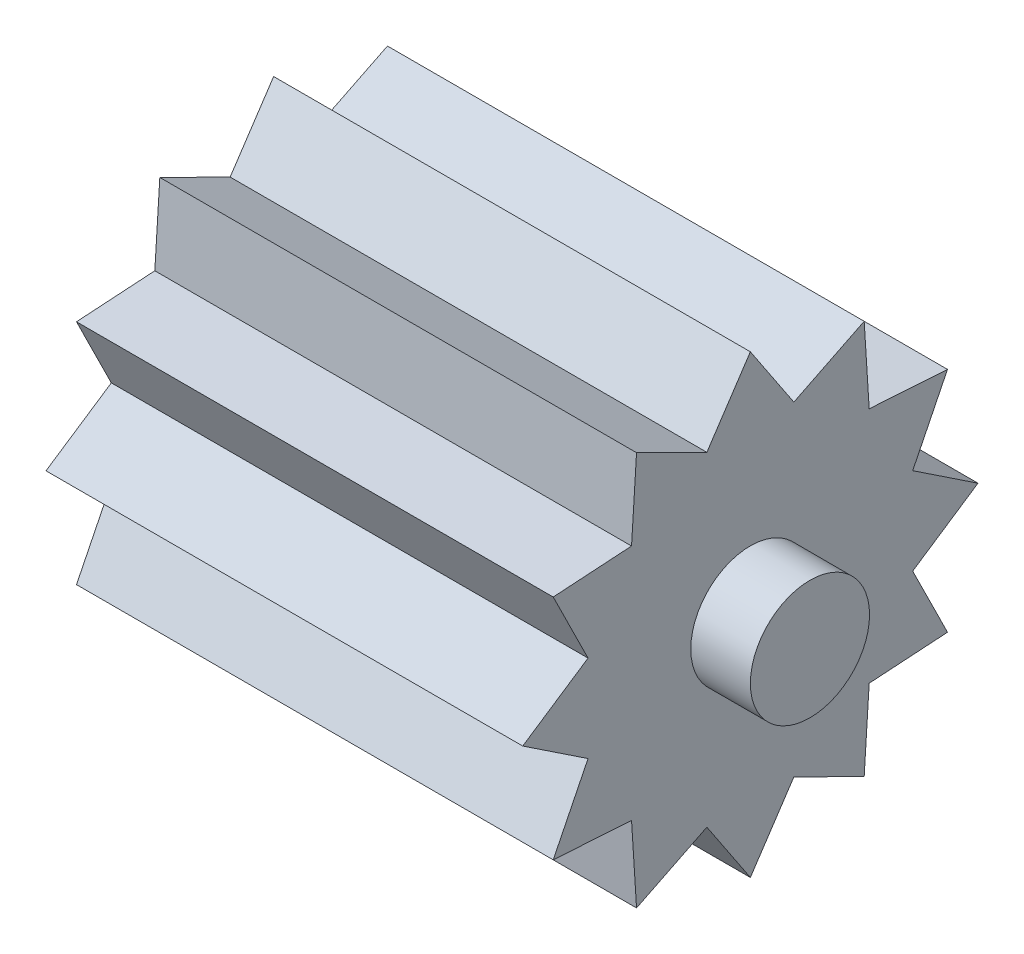
from build123d import *

# Parameters (mm, degrees)
BOSS_EXTRUDE1_DEPTH = 10
SKETCH4_R           = 2.5
BOSS_EXTRUDE3_DEPTH = 2.5


with BuildPart() as part:
    # Sketch1 → Boss-Extrude1 (new body)
    with BuildSketch(Plane(origin=(0, 0, 0), x_dir=(0, 0, -1), z_dir=(1, 0, 0))):
        Polygon((0, 9.55), (1.824674268, 6.809777075), (4.775, 8.270542606), (4.985102807, 4.985102807), (8.270542606, 4.775), (6.809777075, 1.824674268), (9.55, 0), (6.809777075, -1.824674268), (8.270542606, -4.775), (4.985102807, -4.985102807), (4.775, -8.270542606), (1.824674268, -6.809777075), (0, -9.55), (-1.824674268, -6.809777075), (-4.775, -8.270542606), (-4.985102807, -4.985102807), (-8.270542606, -4.775), (-6.809777075, -1.824674268), (-9.55, 0), (-6.809777075, 1.824674268), (-8.270542606, 4.775), (-4.985102807, 4.985102807), (-4.775, 8.270542606), (-1.824674268, 6.809777075), align=None)
    boss_extrude1 = extrude(amount=-BOSS_EXTRUDE1_DEPTH)

    # Sketch4 → Boss-Extrude3 (add)
    with BuildSketch(Plane(origin=(0, 0, 0), x_dir=(0, 0, -1), z_dir=(1, 0, 0))):
        Circle(SKETCH4_R)
    boss_extrude3 = extrude(amount=BOSS_EXTRUDE3_DEPTH)

    # Mirror1: Boss-Extrude1, Boss-Extrude3 across plane
    add(boss_extrude1.mirror(Plane.ZY.offset(10)))
    add(boss_extrude3.mirror(Plane.ZY.offset(10)))


solid = part.part
